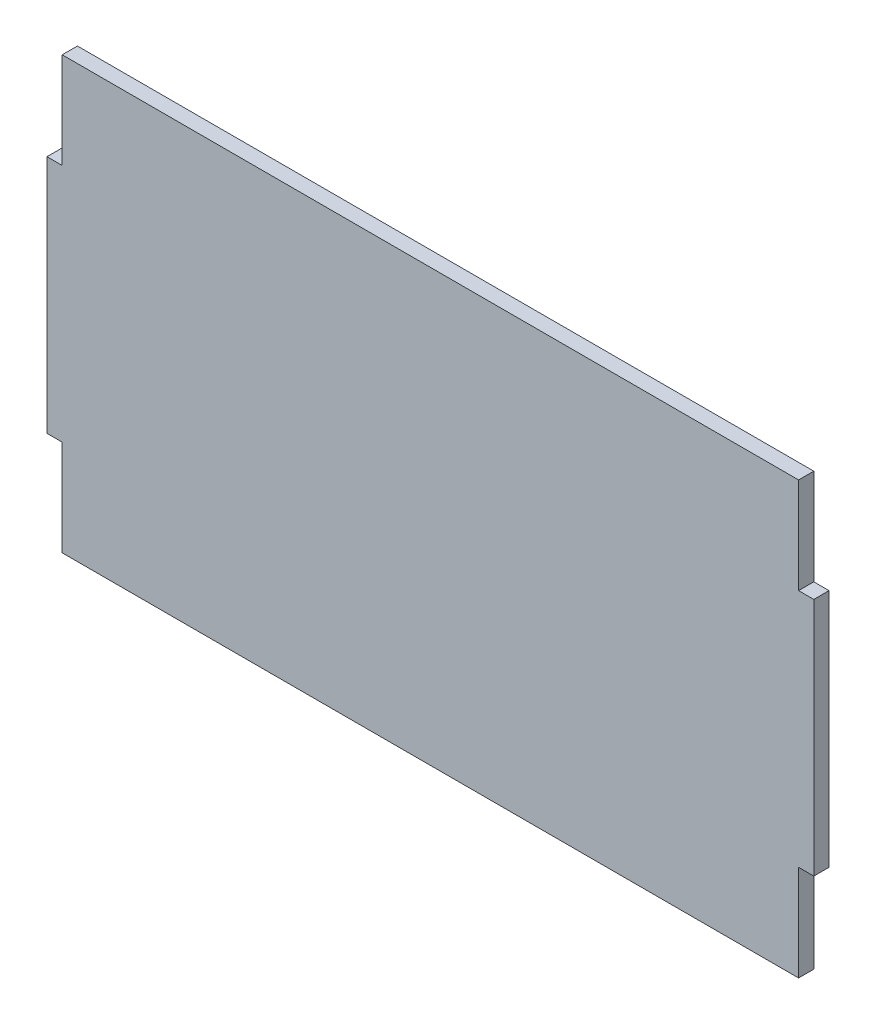
from build123d import *

# Parameters (mm, degrees)
BOSS_EXTRUDE1_DEPTH = 3.175


with BuildPart() as part:
    # Sketch1 → Boss-Extrude1 (new body)
    with BuildSketch(Plane.XY):
        Polygon((0, 0), (153.65, 0), (153.65, 20), (156.825, 20), (156.825, 70), (153.65, 70), (153.65, 90), (0, 90), (0, 70), (-3.175, 70), (-3.175, 20), (0, 20), align=None)
    extrude(amount=BOSS_EXTRUDE1_DEPTH)


solid = part.part
